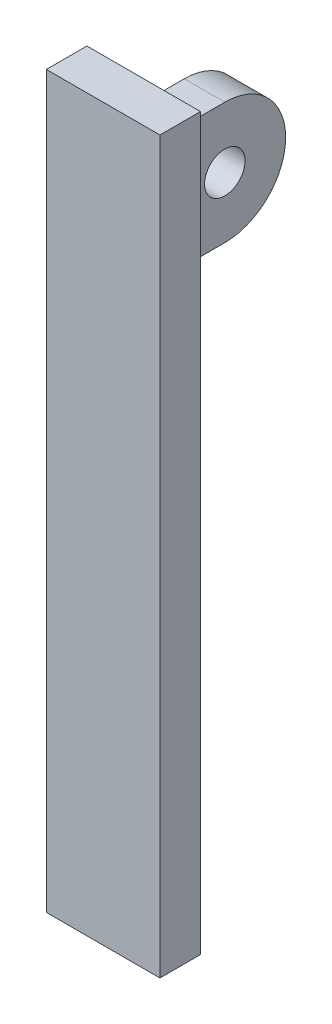
from build123d import *

# Parameters (mm, degrees)
SKETCH1_W           = 28
SKETCH1_H           = 10
BOSS_EXTRUDE1_DEPTH = 270
SKETCH2_W           = 10
SKETCH2_H           = 30
BOSS_EXTRUDE2_DEPTH = 30
SKETCH3_R           = 5
CUT_EXTRUDE1_DEPTH  = 30
SKETCH4_W           = 28
SKETCH4_H           = 90
CUT_EXTRUDE2_DEPTH  = 10


with BuildPart() as part:
    # Sketch1 → Boss-Extrude1 (new body)
    with BuildSketch(Plane(origin=(0, 0, 0), x_dir=(1, 0, 0), z_dir=(0, 1, 0))):
        Rectangle(SKETCH1_W, SKETCH1_H)
    extrude(amount=BOSS_EXTRUDE1_DEPTH)

    # Sketch2 → Boss-Extrude2 (add)
    with BuildSketch(Plane(origin=(0, 0, -5), x_dir=(-1, 0, 0), z_dir=(0, 0, -1))):
        with Locations((0, 155)):
            Rectangle(SKETCH2_W, SKETCH2_H)
    extrude(amount=BOSS_EXTRUDE2_DEPTH)

    # Sketch3 → Cut-Extrude1 (cut)
    with BuildSketch(Plane.ZY.offset(5)):
        with Locations((-20, 155)):
            Circle(SKETCH3_R)
        with BuildLine():
            Line((-20, 140), (-48.501597926, 140))
            Line((-48.501597926, 140), (-48.501597926, 172.313488336))
            Line((-48.501597926, 172.313488336), (-20, 170))
            ThreePointArc((-20, 170), (-35, 155), (-20, 140))
        make_face()
    extrude(amount=-CUT_EXTRUDE1_DEPTH, mode=Mode.SUBTRACT)

    # Sketch4 → Cut-Extrude2 (cut)
    with BuildSketch(Plane(origin=(0, 0, -5), x_dir=(-1, 0, 0), z_dir=(0, 0, -1))):
        with Locations((0, 225)):
            Rectangle(SKETCH4_W, SKETCH4_H)
    extrude(amount=-CUT_EXTRUDE2_DEPTH, mode=Mode.SUBTRACT)


solid = part.part
